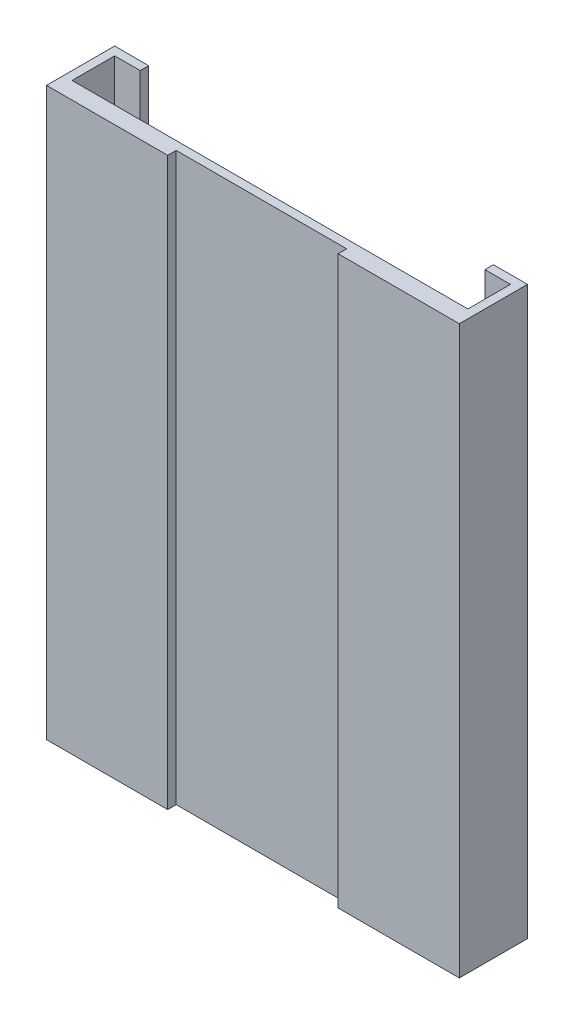
from build123d import *

# Parameters (mm, degrees)
SKETCH1_W           = 19.38
SKETCH1_H           = 26.6
BOSS_EXTRUDE1_DEPTH = 0.8
SKETCH2_W           = 0.4
SKETCH2_H           = 26.6
BOSS_EXTRUDE2_DEPTH = 2.4
SKETCH3_W           = 0.4
SKETCH3_H           = 26.6
BOSS_EXTRUDE3_DEPTH = 2.4
SKETCH4_W           = 8
SKETCH4_H           = 0.4
CUT_EXTRUDE1_DEPTH  = 27.6
SKETCH5_W           = 0.4
SKETCH5_H           = 26.6
BOSS_EXTRUDE4_DEPTH = 1.2
SKETCH6_W           = 0.4
SKETCH6_H           = 26.6
BOSS_EXTRUDE5_DEPTH = 1.2
SKETCH7_W           = 18.58
SKETCH7_H           = 0.4
BOSS_EXTRUDE6_DEPTH = 2.4
SKETCH8_W           = 2
SKETCH8_H           = 0.8
BOSS_EXTRUDE7_DEPTH = 0.8
SKETCH9_W           = 2.2470594
SKETCH9_H           = 0.8
BOSS_EXTRUDE8_DEPTH = 0.8
CUT_EXTRUDE2_DEPTH  = 11.01353


with BuildPart() as part:
    # Sketch1 → Boss-Extrude1 (new body)
    with BuildSketch(Plane.XY):
        Rectangle(SKETCH1_W, SKETCH1_H)
    extrude(amount=-BOSS_EXTRUDE1_DEPTH)

    # Sketch2 → Boss-Extrude2 (add)
    with BuildSketch(Plane(origin=(0, 0, -0.8), x_dir=(-1, 0, 0), z_dir=(0, 0, -1))):
        with Locations((-9.49, 0)):
            Rectangle(SKETCH2_W, SKETCH2_H)
    extrude(amount=BOSS_EXTRUDE2_DEPTH)

    # Sketch3 → Boss-Extrude3 (add)
    with BuildSketch(Plane(origin=(0, 0, -0.8), x_dir=(-1, 0, 0), z_dir=(0, 0, -1))):
        with Locations((9.49, 0)):
            Rectangle(SKETCH3_W, SKETCH3_H)
    extrude(amount=BOSS_EXTRUDE3_DEPTH)

    # Sketch4 → Cut-Extrude1 (cut, through all)
    with BuildSketch(Plane.XZ.offset(13.3)):
        with Locations((0, -0.2)):
            Rectangle(SKETCH4_W, SKETCH4_H)
    extrude(amount=-CUT_EXTRUDE1_DEPTH, mode=Mode.SUBTRACT)

    # Sketch5 → Boss-Extrude4 (add)
    with BuildSketch(Plane.ZY.offset(-9.29)):
        with Locations((-3, 0)):
            Rectangle(SKETCH5_W, SKETCH5_H)
    extrude(amount=BOSS_EXTRUDE4_DEPTH)

    # Sketch6 → Boss-Extrude5 (add)
    with BuildSketch(Plane(origin=(-9.29, 0, 0), x_dir=(0, 0, -1), z_dir=(1, 0, 0))):
        with Locations((3, 0)):
            Rectangle(SKETCH6_W, SKETCH6_H)
    extrude(amount=BOSS_EXTRUDE5_DEPTH)

    # Sketch7 → Boss-Extrude6 (add, through all)
    with BuildSketch(Plane(origin=(0, 0, -0.8), x_dir=(-1, 0, 0), z_dir=(0, 0, -1))):
        with Locations((0, -13.1)):
            Rectangle(SKETCH7_W, SKETCH7_H)
    extrude(amount=BOSS_EXTRUDE6_DEPTH)

    # Sketch8 → Boss-Extrude7 (add)
    with BuildSketch(Plane(origin=(0, 0, -0.8), x_dir=(-1, 0, 0), z_dir=(0, 0, -1))):
        with Locations((-4.445, 12.9)):
            Rectangle(SKETCH8_W, SKETCH8_H)
    extrude(amount=BOSS_EXTRUDE7_DEPTH)

    # Sketch9 → Boss-Extrude8 (add)
    with BuildSketch(Plane(origin=(0, 0, -0.8), x_dir=(-1, 0, 0), z_dir=(0, 0, -1))):
        with Locations((4.445, 12.9)):
            Rectangle(SKETCH9_W, SKETCH9_H)
    extrude(amount=BOSS_EXTRUDE8_DEPTH)

    # Sketch10 → Cut-Extrude2 (cut)
    with BuildSketch(Plane.ZY.offset(5.5685297)):
        Polygon((-1.6, 12.5), (-0.8, 13.3), (-1.6, 13.3), align=None)
    extrude(amount=-CUT_EXTRUDE2_DEPTH, mode=Mode.SUBTRACT)


solid = part.part
